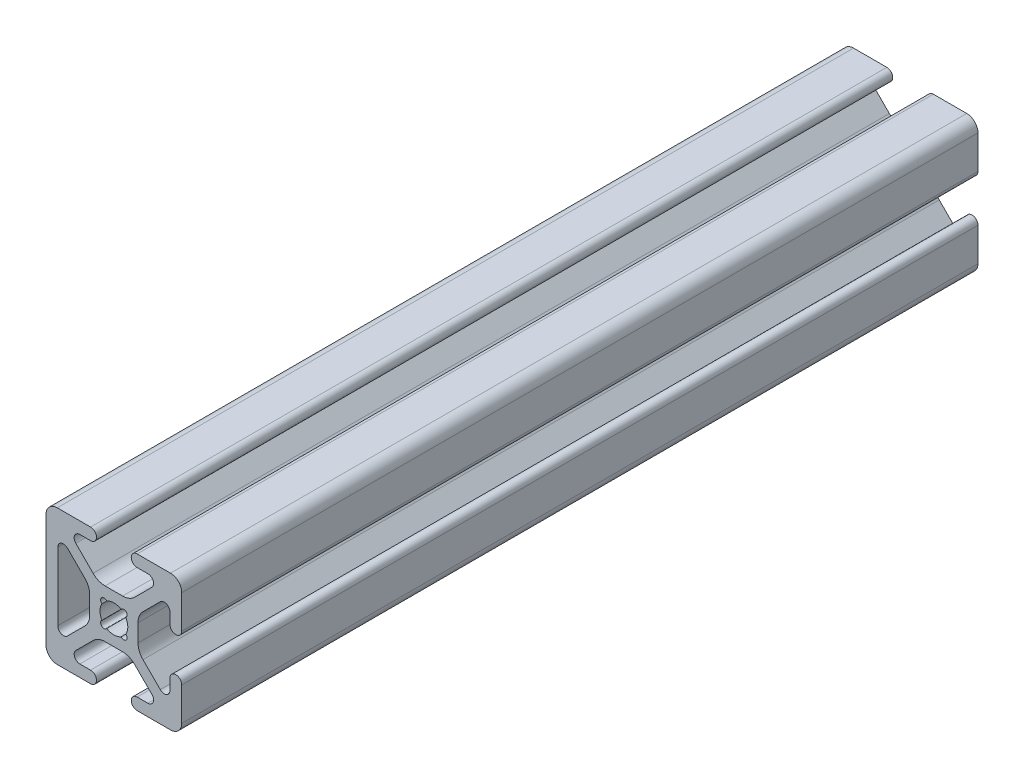
from build123d import *

# Parameters (mm, degrees)
BOSS_EXTRUDE1_DEPTH = 149


with BuildPart() as part:
    # Sketch1 → Boss-Extrude1 (new body)
    with BuildSketch(Plane.XY.offset(12.7)):
        with BuildLine():
            Line((-12.7, 10.5918), (-12.7, -10.5918))
            ThreePointArc((-12.7, -10.5918), (-12.082522516, -12.082522516), (-10.5918, -12.7))
            Line((-10.5918, -12.7), (-4.3561, -12.7))
            ThreePointArc((-4.3561, -12.7), (-3.2512, -11.5951), (-4.3561, -10.4902))
            Line((-4.3561, -10.4902), (-6.370083784, -10.4902))
            ThreePointArc((-6.370083784, -10.4902), (-7.34885674, -9.836204819), (-7.119204173, -8.681663397))
            Line((-7.119204173, -8.681663397), (-3.884643888, -5.447103113))
            ThreePointArc((-3.884643888, -5.447103113), (-2.854599756, -4.758849627), (-1.639579858, -4.517167143))
            Line((-1.639579858, -4.517167143), (1.639579858, -4.517167143))
            ThreePointArc((1.639579858, -4.517167143), (2.854599756, -4.758849627), (3.884643888, -5.447103113))
            Line((3.884643888, -5.447103113), (7.119204173, -8.681663397))
            ThreePointArc((7.119204173, -8.681663397), (7.34885674, -9.836204819), (6.370083784, -10.4902))
            Line((6.370083784, -10.4902), (4.356099789, -10.4902))
            ThreePointArc((4.356099789, -10.4902), (3.251199789, -11.5951), (4.356099789, -12.7))
            Line((4.356099789, -12.7), (10.5918, -12.7))
            ThreePointArc((10.5918, -12.7), (12.082522516, -12.082522516), (12.7, -10.5918))
            Line((12.7, -10.5918), (12.7, -4.3561))
            ThreePointArc((12.7, -4.3561), (11.5951, -3.2512), (10.4902, -4.3561))
            Line((10.4902, -4.3561), (10.4902, -6.370083784))
            ThreePointArc((10.4902, -6.370083784), (9.836204819, -7.34885674), (8.681663397, -7.119204173))
            Line((8.681663397, -7.119204173), (5.447103113, -3.884643888))
            ThreePointArc((5.447103113, -3.884643888), (4.758849627, -2.854599756), (4.517167143, -1.639579858))
            Line((4.517167143, -1.639579858), (4.517167143, 1.639579858))
            ThreePointArc((4.517167143, 1.639579858), (4.758849627, 2.854599756), (5.447103113, 3.884643888))
            Line((5.447103113, 3.884643888), (8.681663397, 7.119204173))
            ThreePointArc((8.681663397, 7.119204173), (9.836204819, 7.34885674), (10.4902, 6.370083784))
            Line((10.4902, 6.370083784), (10.4902, 4.3561))
            ThreePointArc((10.4902, 4.3561), (11.5951, 3.2512), (12.7, 4.3561))
            Line((12.7, 4.3561), (12.7, 10.5918))
            ThreePointArc((12.7, 10.5918), (12.082522516, 12.082522516), (10.5918, 12.7))
            Line((10.5918, 12.7), (4.3561, 12.7))
            ThreePointArc((4.3561, 12.7), (3.2512, 11.5951), (4.3561, 10.4902))
            Line((4.3561, 10.4902), (6.370083784, 10.4902))
            ThreePointArc((6.370083784, 10.4902), (7.34885674, 9.836204819), (7.119204173, 8.681663397))
            Line((7.119204173, 8.681663397), (3.884643888, 5.447103113))
            ThreePointArc((3.884643888, 5.447103113), (2.854599756, 4.758849627), (1.639579858, 4.517167143))
            Line((1.639579858, 4.517167143), (-1.639579858, 4.517167143))
            ThreePointArc((-1.639579858, 4.517167143), (-2.854599756, 4.758849627), (-3.884643888, 5.447103113))
            Line((-3.884643888, 5.447103113), (-7.119204173, 8.681663397))
            ThreePointArc((-7.119204173, 8.681663397), (-7.34885674, 9.836204819), (-6.370083784, 10.4902))
            Line((-6.370083784, 10.4902), (-4.356099789, 10.4902))
            ThreePointArc((-4.356099789, 10.4902), (-3.251199789, 11.5951), (-4.356099789, 12.7))
            Line((-4.356099789, 12.7), (-10.5918, 12.7))
            ThreePointArc((-10.5918, 12.7), (-12.082522516, 12.082522516), (-12.7, 10.5918))
        make_face()
        with BuildLine():
            Line((-8.681663397, 7.119204173), (-5.447103113, 3.884643888))
            ThreePointArc((-5.447103113, 3.884643888), (-4.758849627, 2.854599756), (-4.517167143, 1.639579858))
            Line((-4.517167143, 1.639579858), (-4.517167143, -1.639579858))
            ThreePointArc((-4.517167143, -1.639579858), (-4.758849627, -2.854599756), (-5.447103113, -3.884643888))
            Line((-5.447103113, -3.884643888), (-8.681663397, -7.119204173))
            ThreePointArc((-8.681663397, -7.119204173), (-9.836204819, -7.34885674), (-10.4902, -6.370083784))
            Line((-10.4902, -6.370083784), (-10.4902, 6.370083784))
            ThreePointArc((-10.4902, 6.370083784), (-9.836204819, 7.34885674), (-8.681663397, 7.119204173))
        make_face(mode=Mode.SUBTRACT)
        with BuildLine():
            ThreePointArc((-2.231856261, 1.340533427), (-2.28996531, 2.28996531), (-1.340533427, 2.231856261))
            ThreePointArc((-1.340533427, 2.231856261), (-1.1e-08, 2.603499998), (1.340533408, 2.231856273))
            ThreePointArc((1.340533408, 2.231856273), (2.28996531, 2.28996533), (2.231856262, 1.340533427))
            ThreePointArc((2.231856262, 1.340533427), (2.603499999, 1.1e-08), (2.231856274, -1.340533408))
            ThreePointArc((2.231856274, -1.340533408), (2.289965331, -2.28996531), (1.340533428, -2.231856262))
            ThreePointArc((1.340533428, -2.231856262), (6e-09, -2.603499999), (-1.340533417, -2.231856268))
            ThreePointArc((-1.340533417, -2.231856268), (-2.28996532, -2.28996532), (-2.231856267, -1.340533417))
            ThreePointArc((-2.231856267, -1.340533417), (-2.603499998, 6e-09), (-2.231856261, 1.340533427))
        make_face(mode=Mode.SUBTRACT)
    extrude(amount=-BOSS_EXTRUDE1_DEPTH)


solid = part.part
